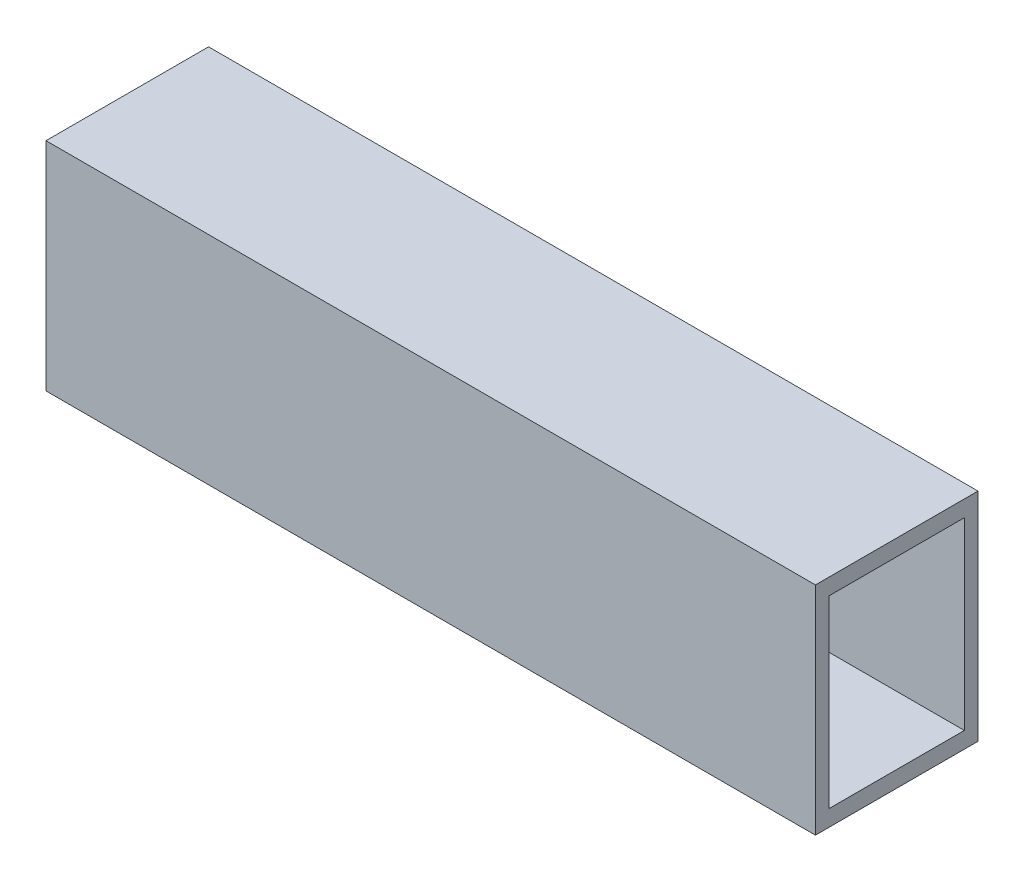
from build123d import *

# Parameters (mm, degrees)
CROQUIS1_W              = 30
CROQUIS1_H              = 40
CROQUIS1_W_2            = 24.961062678
CROQUIS1_H_2            = 34
SALIENTE_EXTRUIR1_DEPTH = 142


with BuildPart() as part:
    # Croquis1 → Saliente-Extruir1 (new body)
    with BuildSketch(Plane(origin=(0, 0, 0), x_dir=(0, 0, -1), z_dir=(1, 0, 0))):
        Rectangle(CROQUIS1_W, CROQUIS1_H)
        Rectangle(CROQUIS1_W_2, CROQUIS1_H_2, mode=Mode.SUBTRACT)
    extrude(amount=SALIENTE_EXTRUIR1_DEPTH)


solid = part.part
